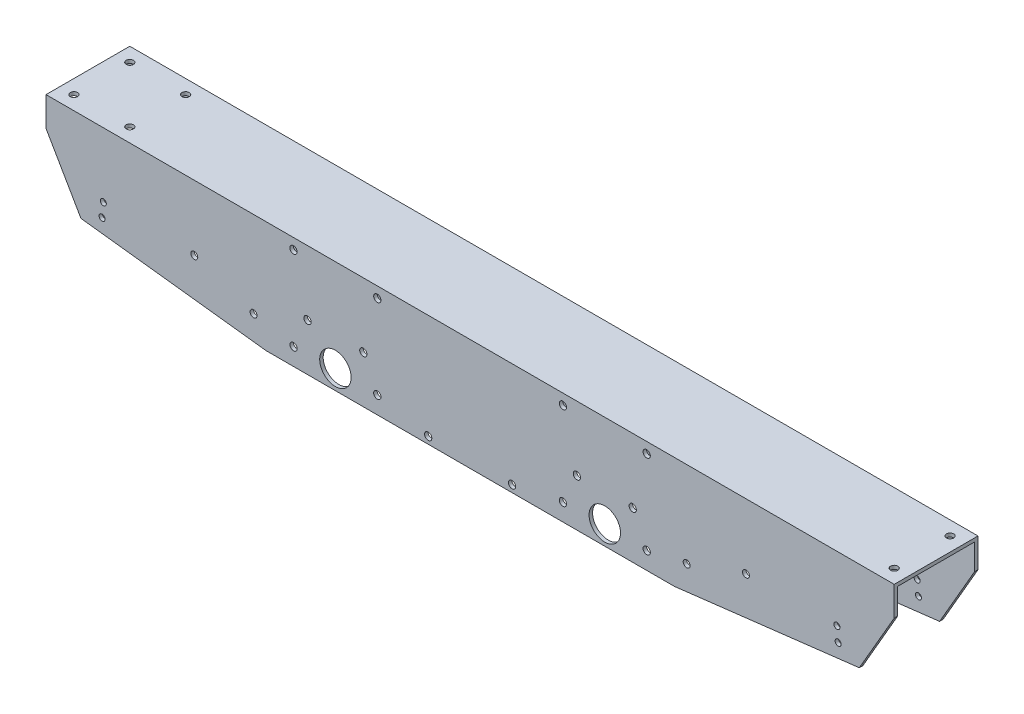
from build123d import *

# Parameters (mm, degrees)
BOSS_EXTRUDE1_DEPTH                     = 385.705756272
SKETCH2_R                               = 2.749999961
SKETCH2_R_2                             = 2.75
SKETCH2_R_3                             = 3.302
SKETCH2_R_4                             = 14.2875
AXLES_DEPTH                             = 141.732
FLANIGAN_MOUNTING_HOLES_R               = 3.3
FLANIGAN_MOUNTING_HOLES_EXTRUSION_DEPTH = 77.2
BEVELED_ENDS_DEPTH                      = 101.6
SKETCH32_R                              = 3.3
BELT_SHIELD_HOLES_DEPTH                 = 77.2
SKETCH37_R                              = 3.3
TOP_HOLES_DEPTH                         = 102.6
SKETCH38_R                              = 3.15
CUT_EXTRUDE1_DEPTH                      = 77.2


with BuildPart() as part:
    # Sketch1 → Boss-Extrude1 (new body, symmetric)
    with BuildSketch(Plane(origin=(0, 0, 0), x_dir=(0, 0, -1), z_dir=(1, 0, 0))):
        Polygon((-38.1, 50.8), (38.1, 50.8), (38.1, -50.8), (34.925, -50.8), (34.925, 47.625), (-34.925, 47.625), (-34.925, -50.8), (-38.1, -50.8), align=None)
    extrude(amount=BOSS_EXTRUDE1_DEPTH, both=True)

    # Sketch2 → Axles (cut)
    with BuildSketch(Plane.XY.offset(38.1)):
        with Locations((-333.577237048, -7.874)):
            Circle(SKETCH2_R)
        with Locations((334.720333616, -20.574)):
            Circle(SKETCH2_R_2)
        with Locations((333.577237048, -7.874)):
            Circle(SKETCH2_R)
        with Locations((84.4, -35.12)):
            Circle(SKETCH2_R_3)
        with Locations((-160.6, -35.12)):
            Circle(SKETCH2_R_3)
        with Locations((-160.6, 41.08)):
            Circle(SKETCH2_R_3)
        with Locations((-122.5, -33.274)):
            Circle(SKETCH2_R_4)
        with Locations((-334.720333616, -20.574)):
            Circle(SKETCH2_R_2)
        with Locations((-84.4, 41.08)):
            Circle(SKETCH2_R_3)
        with Locations((-84.4, -35.12)):
            Circle(SKETCH2_R_3)
        with Locations((160.6, -35.12)):
            Circle(SKETCH2_R_3)
        with Locations((84.4, 41.08)):
            Circle(SKETCH2_R_3)
        with Locations((160.6, 41.08)):
            Circle(SKETCH2_R_3)
        with Locations((122.5, -33.274)):
            Circle(SKETCH2_R_4)
    extrude(amount=-AXLES_DEPTH, mode=Mode.SUBTRACT)

    # Flanigan mounting holes → Flanigan mounting holes extrusion (cut, through all)
    with BuildSketch(Plane.XY.offset(38.1)):
        with Locations((-147.9, -7.87)):
            Circle(FLANIGAN_MOUNTING_HOLES_R)
        with Locations((97.1, -7.87)):
            Circle(FLANIGAN_MOUNTING_HOLES_R)
        with Locations((-97.1, -7.87)):
            Circle(FLANIGAN_MOUNTING_HOLES_R)
        with Locations((147.9, -7.87)):
            Circle(FLANIGAN_MOUNTING_HOLES_R)
    extrude(amount=-FLANIGAN_MOUNTING_HOLES_EXTRUSION_DEPTH, mode=Mode.SUBTRACT)

    # Sketch16 → Beveled ends (cut)
    with BuildSketch(Plane.XY.offset(38.1)):
        Polygon((-353.951491467, -30.8), (-185.705756272, -50.8), (-385.705756272, -50.8), (-385.705756272, 24.2), align=None)
        Polygon((385.705756272, -50.8), (185.705756272, -50.8), (353.951491467, -30.8), (385.705756272, 24.2), align=None)
    extrude(amount=-BEVELED_ENDS_DEPTH, mode=Mode.SUBTRACT)

    # Sketch32 → Belt shield holes (cut, through all)
    with BuildSketch(Plane(origin=(0, 0, -38.1), x_dir=(-1, 0, 0), z_dir=(0, 0, -1))):
        with Locations((-38.1, -44.45)):
            Circle(SKETCH32_R)
        with Locations((38.1, -44.45)):
            Circle(SKETCH32_R)
    extrude(amount=-BELT_SHIELD_HOLES_DEPTH, mode=Mode.SUBTRACT)

    # Sketch37 → Top holes (cut, through all)
    with BuildSketch(Plane(origin=(0, 50.8, 0), x_dir=(1, 0, 0), z_dir=(0, 1, 0))):
        with Locations((373.005756272, 25.4)):
            Circle(SKETCH37_R)
        with Locations((373.005756272, -25.4)):
            Circle(SKETCH37_R)
        with Locations((-322.205756272, 25.4)):
            Circle(SKETCH37_R)
        with Locations((-322.205756272, -25.4)):
            Circle(SKETCH37_R)
        with Locations((-373.005756272, 25.4)):
            Circle(SKETCH37_R)
        with Locations((-373.005756272, -25.4)):
            Circle(SKETCH37_R)
    extrude(amount=-TOP_HOLES_DEPTH, mode=Mode.SUBTRACT)

    # Sketch38 → Cut-Extrude1 (cut, through all)
    with BuildSketch(Plane.XY.offset(38.1)):
        with Locations((-250.831756272, -8.382)):
            Circle(SKETCH38_R)
        with Locations((-196.924747031, -27.359798996)):
            Circle(SKETCH38_R)
        with Locations((196.924747031, -27.359798996)):
            Circle(SKETCH38_R)
        with Locations((250.831756272, -8.382)):
            Circle(SKETCH38_R)
    extrude(amount=-CUT_EXTRUDE1_DEPTH, mode=Mode.SUBTRACT)


solid = part.part
